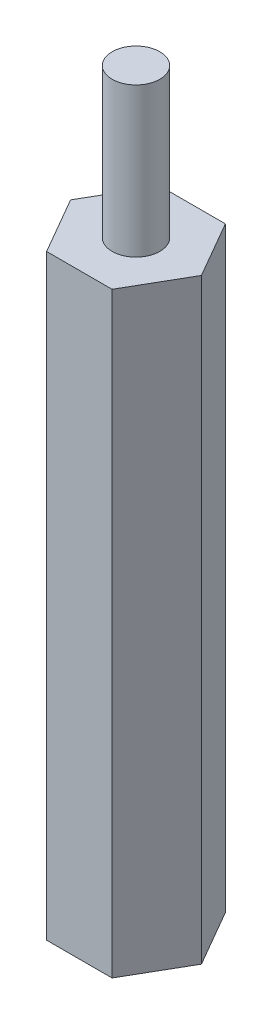
from build123d import *

# Parameters (mm, degrees)
BOSS_EXTRUDE1_DEPTH = 25.4
SKETCH2_R           = 1.016
BOSS_EXTRUDE2_DEPTH = 6.35
SKETCH3_R           = 1.016
CUT_EXTRUDE1_DEPTH  = 6.35


with BuildPart() as part:
    # Sketch1 → Boss-Extrude1 (new body)
    with BuildSketch(Plane(origin=(0, 0, 0), x_dir=(1, 0, 0), z_dir=(0, 1, 0))):
        Polygon((1.3931462, -2.413), (2.786292399, 0), (1.3931462, 2.413), (-1.3931462, 2.413), (-2.786292399, 0), (-1.3931462, -2.413), align=None)
    extrude(amount=BOSS_EXTRUDE1_DEPTH)

    # Sketch2 → Boss-Extrude2 (add)
    with BuildSketch(Plane(origin=(0, 25.4, 0), x_dir=(1, 0, 0), z_dir=(0, 1, 0))):
        Circle(SKETCH2_R)
    extrude(amount=BOSS_EXTRUDE2_DEPTH)

    # Sketch3 → Cut-Extrude1 (cut)
    with BuildSketch(Plane.XZ):
        Circle(SKETCH3_R)
    extrude(amount=-CUT_EXTRUDE1_DEPTH, mode=Mode.SUBTRACT)


solid = part.part
